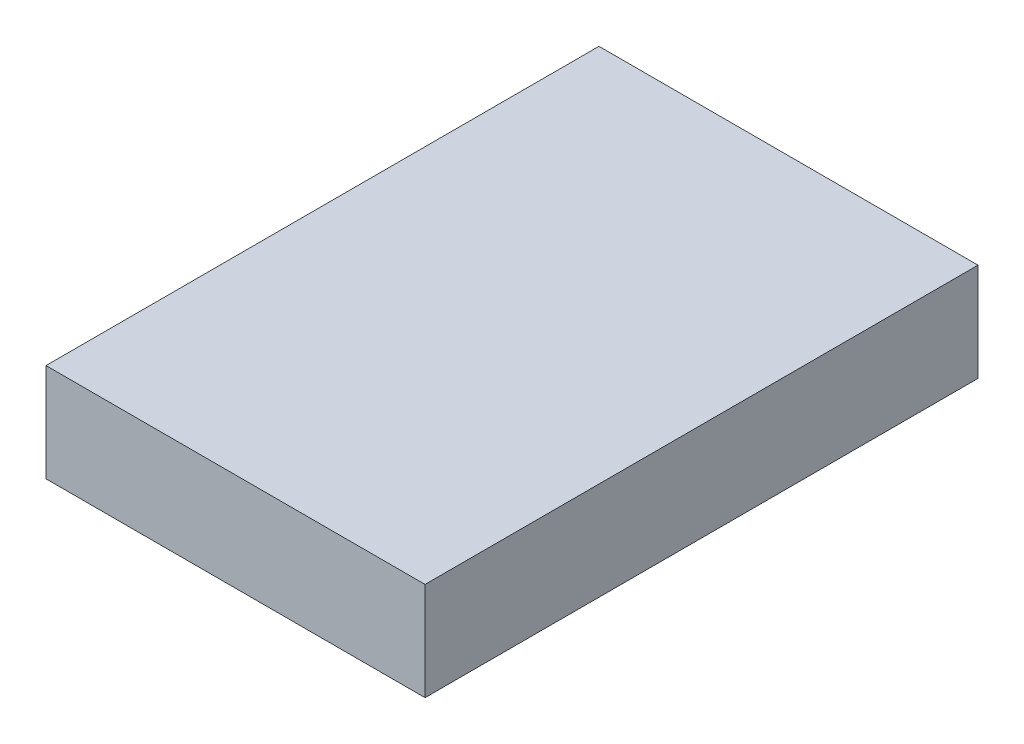
from build123d import *

# Parameters (mm, degrees)
SKETCH_1_W      = 85
SKETCH_1_H      = 124
EXTRUDE_1_DEPTH = 22


with BuildPart() as part:
    # Эскиз1 → Бобышка-Вытянуть1 (new body)
    with BuildSketch(Plane(origin=(0, 0, 0), x_dir=(1, 0, 0), z_dir=(0, 1, 0))):
        Rectangle(SKETCH_1_W, SKETCH_1_H)
    extrude(amount=EXTRUDE_1_DEPTH)


solid = part.part
